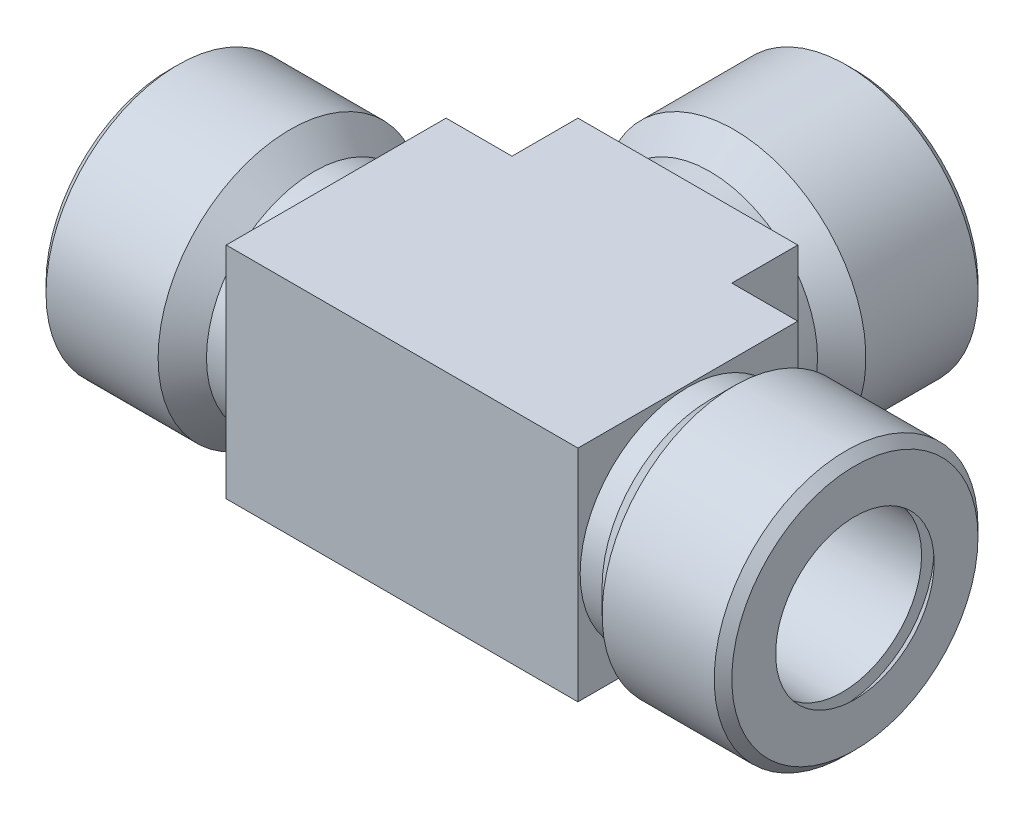
from build123d import *

# Parameters (mm, degrees)
SKETCH1_W            = 40.64
SKETCH1_H            = 33.02
BOSS_EXTRUDE1_DEPTH  = 25.4
SKETCH2_W            = 7.62
SKETCH2_H            = 7.62
CUT_EXTRUDE1_DEPTH   = 26.4
SKETCH3_W            = 7.62
SKETCH3_H            = 7.62
CUT_EXTRUDE2_DEPTH   = 26.4
SKETCH4_R            = 12.446
BOSS_EXTRUDE2_DEPTH  = 2.54
SKETCH5_R            = 12.446
BOSS_EXTRUDE3_DEPTH  = 2.794
BOSS_EXTRUDE3_TAPER  = -45
SKETCH6_R            = 15.24
BOSS_EXTRUDE4_DEPTH  = 13.97
SKETCH7_R            = 12.446
BOSS_EXTRUDE5_DEPTH  = 2.54
SKETCH8_R            = 12.446
BOSS_EXTRUDE6_DEPTH  = 2.794
BOSS_EXTRUDE6_TAPER  = -45
SKETCH9_R            = 15.24
BOSS_EXTRUDE7_DEPTH  = 13.97
SKETCH10_R           = 12.446
BOSS_EXTRUDE8_DEPTH  = 2.54
SKETCH11_R           = 12.446
BOSS_EXTRUDE9_DEPTH  = 2.794
BOSS_EXTRUDE9_TAPER  = -45
SKETCH12_R           = 15.24
BOSS_EXTRUDE10_DEPTH = 13.97
SKETCH13_R           = 9.271
CUT_EXTRUDE3_DEPTH   = 52.10556
CUT_EXTRUDE4_REACH   = 43.293
SKETCH14_R           = 9.271
SKETCH15_R           = 10.611739
CUT_EXTRUDE5_DEPTH   = 1.451356
CUT_EXTRUDE5_TAPER   = 45
SKETCH16_R           = 8.849363403
CUT_EXTRUDE6_DEPTH   = 12.119864
CUT_EXTRUDE6_TAPER   = -1.47
SKETCH17_R           = 10.611739
CUT_EXTRUDE7_DEPTH   = 1.451356
CUT_EXTRUDE7_TAPER   = 45
SKETCH18_R           = 8.849363403
CUT_EXTRUDE8_DEPTH   = 12.119864
CUT_EXTRUDE8_TAPER   = -1.47
SKETCH21_R           = 8.849363403
CUT_EXTRUDE9_DEPTH   = 12.119864
CUT_EXTRUDE9_TAPER   = -1.47
CHAMFER1_SIZE        = 1.016
CHAMFER2_SIZE        = 1.016
CHAMFER3_SIZE        = 1.016


with BuildPart() as part:
    # Sketch1 → Boss-Extrude1 (new body)
    with BuildSketch(Plane(origin=(0, 12.7, 0), x_dir=(-1, 0, 0), z_dir=(0, 1, 0))):
        with Locations((-39.624, -3.81)):
            Rectangle(SKETCH1_W, SKETCH1_H)
    extrude(amount=-BOSS_EXTRUDE1_DEPTH)

    # Sketch2 → Cut-Extrude1 (cut, through all)
    with BuildSketch(Plane.XZ.offset(12.7)):
        with Locations((56.134, -16.51)):
            Rectangle(SKETCH2_W, SKETCH2_H)
    extrude(amount=-CUT_EXTRUDE1_DEPTH, mode=Mode.SUBTRACT)

    # Sketch3 → Cut-Extrude2 (cut, through all)
    with BuildSketch(Plane.XZ.offset(12.7)):
        with Locations((23.114, -16.51)):
            Rectangle(SKETCH3_W, SKETCH3_H)
    extrude(amount=-CUT_EXTRUDE2_DEPTH, mode=Mode.SUBTRACT)

    # Sketch4 → Boss-Extrude2 (add)
    with BuildSketch(Plane.ZY.offset(-19.304)):
        Circle(SKETCH4_R)
    extrude(amount=BOSS_EXTRUDE2_DEPTH)

    # Sketch5 → Boss-Extrude3 (add)
    with BuildSketch(Plane.ZY.offset(-16.764)):
        Circle(SKETCH5_R)
    extrude(amount=BOSS_EXTRUDE3_DEPTH, taper=BOSS_EXTRUDE3_TAPER)

    # Sketch6 → Boss-Extrude4 (add)
    with BuildSketch(Plane.ZY.offset(-13.97)):
        Circle(SKETCH6_R)
    extrude(amount=BOSS_EXTRUDE4_DEPTH)

    # Sketch7 → Boss-Extrude5 (add)
    with BuildSketch(Plane(origin=(59.944, 0, 0), x_dir=(0, 0, -1), z_dir=(1, 0, 0))):
        Circle(SKETCH7_R)
    extrude(amount=BOSS_EXTRUDE5_DEPTH)

    # Sketch8 → Boss-Extrude6 (add)
    with BuildSketch(Plane(origin=(62.484, 0, 0), x_dir=(0, 0, -1), z_dir=(1, 0, 0))):
        Circle(SKETCH8_R)
    extrude(amount=BOSS_EXTRUDE6_DEPTH, taper=BOSS_EXTRUDE6_TAPER)

    # Sketch9 → Boss-Extrude7 (add)
    with BuildSketch(Plane(origin=(65.278, 0, 0), x_dir=(0, 0, -1), z_dir=(1, 0, 0))):
        Circle(SKETCH9_R)
    extrude(amount=BOSS_EXTRUDE7_DEPTH)

    # Sketch10 → Boss-Extrude8 (add)
    with BuildSketch(Plane(origin=(0, 0, -20.32), x_dir=(-1, 0, 0), z_dir=(0, 0, -1))):
        with Locations((-39.624, 0)):
            Circle(SKETCH10_R)
    extrude(amount=BOSS_EXTRUDE8_DEPTH)

    # Sketch11 → Boss-Extrude9 (add)
    with BuildSketch(Plane(origin=(0, 0, -22.86), x_dir=(-1, 0, 0), z_dir=(0, 0, -1))):
        with Locations((-39.624, 0)):
            Circle(SKETCH11_R)
    extrude(amount=BOSS_EXTRUDE9_DEPTH, taper=BOSS_EXTRUDE9_TAPER)

    # Sketch12 → Boss-Extrude10 (add)
    with BuildSketch(Plane(origin=(0, 0, -25.654), x_dir=(-1, 0, 0), z_dir=(0, 0, -1))):
        with Locations((-39.624, 0)):
            Circle(SKETCH12_R)
    extrude(amount=BOSS_EXTRUDE10_DEPTH)

    # Sketch13 → Cut-Extrude3 (cut)
    with BuildSketch(Plane(origin=(13.57122, 0, 0), x_dir=(0, -1, 0), z_dir=(-1, 0, 0))):
        Circle(SKETCH13_R)
    extrude(amount=-CUT_EXTRUDE3_DEPTH, mode=Mode.SUBTRACT)

    # Sketch14 → Cut-Extrude4 (cut, up to next)
    with BuildSketch(Plane(origin=(0, 0, -26.05278), x_dir=(-1, 0, 0), z_dir=(0, 0, -1)), mode=Mode.PRIVATE) as cut_extrude4_sk1:
        with Locations((-39.624, 0)):
            Circle(SKETCH14_R)
    cut_extrude4_tool1 = extrude(cut_extrude4_sk1.sketch, amount=-CUT_EXTRUDE4_REACH, mode=Mode.PRIVATE) & part.part
    add(cut_extrude4_tool1.solids().sort_by_distance((39.624, 0, -26.05278))[0], mode=Mode.SUBTRACT)

    # Sketch15 → Cut-Extrude5 (cut)
    with BuildSketch(Plane(origin=(0, 0, -39.624), x_dir=(-1, 0, 0), z_dir=(0, 0, -1))):
        with Locations((-39.624, 0)):
            Circle(SKETCH15_R)
    extrude(amount=-CUT_EXTRUDE5_DEPTH, taper=CUT_EXTRUDE5_TAPER, mode=Mode.SUBTRACT)

    # Sketch16 → Cut-Extrude6 (cut)
    with BuildSketch(Plane.XY.offset(-26.05278)):
        with Locations((39.624, 0)):
            Circle(SKETCH16_R)
    extrude(amount=-CUT_EXTRUDE6_DEPTH, taper=CUT_EXTRUDE6_TAPER, mode=Mode.SUBTRACT)

    # Sketch17 → Cut-Extrude7 (cut)
    with BuildSketch(Plane.ZY):
        Circle(SKETCH17_R)
    extrude(amount=-CUT_EXTRUDE7_DEPTH, taper=CUT_EXTRUDE7_TAPER, mode=Mode.SUBTRACT)

    # Sketch18 → Cut-Extrude8 (cut)
    with BuildSketch(Plane(origin=(13.57122, 0, 0), x_dir=(0, 0, -1), z_dir=(1, 0, 0))):
        Circle(SKETCH18_R)
    extrude(amount=-CUT_EXTRUDE8_DEPTH, taper=CUT_EXTRUDE8_TAPER, mode=Mode.SUBTRACT)

    # Sketch19 → Hole1 (revolve, cut)
    with BuildSketch(Plane(origin=(79.248, 0, 0), x_dir=(0, 0, -1), z_dir=(0, 1, 0))):
        Polygon((0, 0), (0, 1.451356), (10.611739, 1.451356), (9.160383, 0), align=None)
    revolve(axis=Axis((-30.752, 0, 0), (1, 0, 0)), mode=Mode.SUBTRACT)

    # Sketch21 → Cut-Extrude9 (cut)
    with BuildSketch(Plane.ZY.offset(-65.67678)):
        Circle(SKETCH21_R)
    extrude(amount=-CUT_EXTRUDE9_DEPTH, taper=CUT_EXTRUDE9_TAPER, mode=Mode.SUBTRACT)

    # Chamfer1
    chamfer1_edges = [part.edges().sort_by_distance(p)[0] for p in [
        (0, 0, -15.24),
    ]]
    chamfer(chamfer1_edges, length=CHAMFER1_SIZE)

    # Chamfer2
    chamfer2_edges = [part.edges().sort_by_distance(p)[0] for p in [
        (79.248, 0, 15.24),
    ]]
    chamfer(chamfer2_edges, length=CHAMFER2_SIZE)

    # Chamfer3
    chamfer3_edges = [part.edges().sort_by_distance(p)[0] for p in [
        (54.864, 0, -39.624),
    ]]
    chamfer(chamfer3_edges, length=CHAMFER3_SIZE)


solid = part.part
